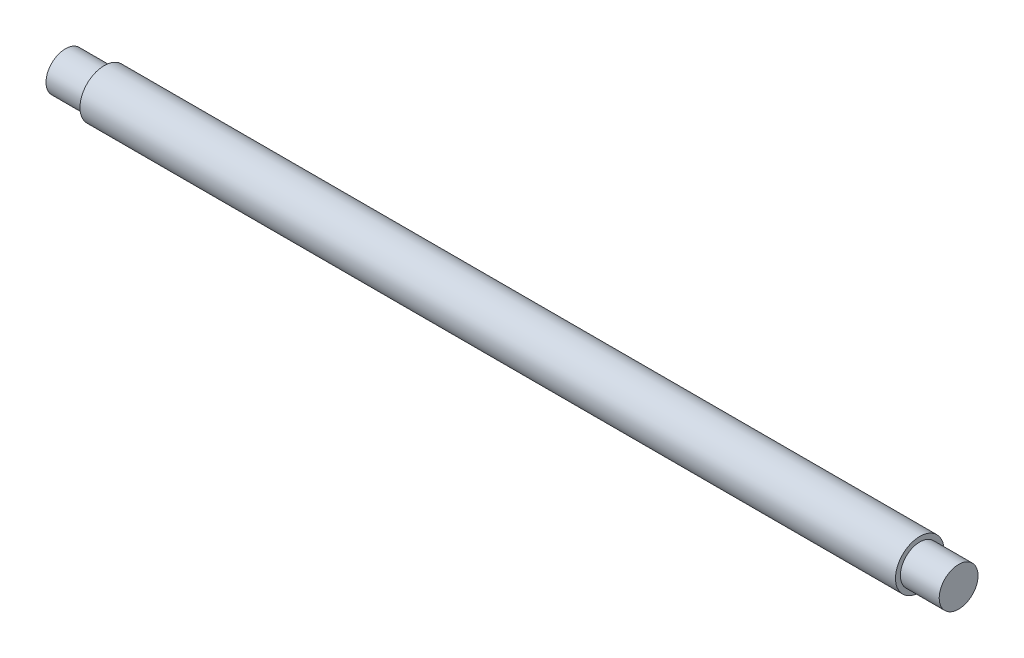
from build123d import *

# Parameters (mm, degrees)
SKETCH1_R           = 12.5
BOSS_EXTRUDE1_DEPTH = 230
SKETCH2_R           = 12.5
SKETCH2_R_2         = 10
CUT_EXTRUDE1_DEPTH  = 20


with BuildPart() as part:
    # Sketch1 → Boss-Extrude1 (new body, symmetric)
    with BuildSketch(Plane(origin=(0, 0, 0), x_dir=(0, 0, -1), z_dir=(1, 0, 0))):
        Circle(SKETCH1_R)
    extrude(amount=BOSS_EXTRUDE1_DEPTH, both=True)

    # Sketch2 → Cut-Extrude1 (cut)
    with BuildSketch(Plane.ZY.offset(230)):
        Circle(SKETCH2_R)
        Circle(SKETCH2_R_2, mode=Mode.SUBTRACT)
    cut_extrude1 = extrude(amount=-CUT_EXTRUDE1_DEPTH, mode=Mode.SUBTRACT)

    # Mirror1: Cut-Extrude1 across plane
    add(cut_extrude1.mirror(Plane(origin=(0, 0, 0), x_dir=(0, 0, 1), z_dir=(1, 0, 0))), mode=Mode.SUBTRACT)


solid = part.part
